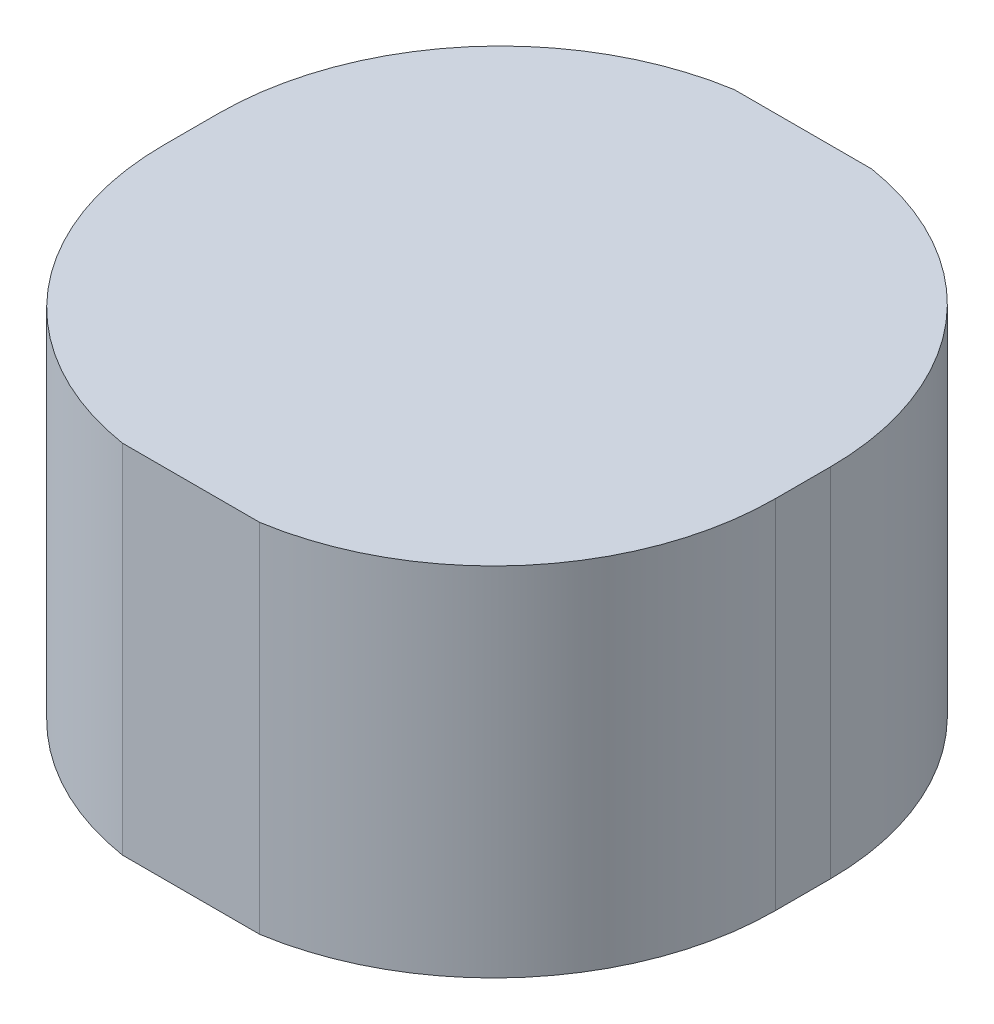
from build123d import *

# Parameters (mm, degrees)
BOSS_EXTRUDE1_DEPTH = 130


with BuildPart() as part:
    # Sketch1 → Boss-Extrude1 (new body)
    with BuildSketch(Plane(origin=(0, 0, 0), x_dir=(1, 0, 0), z_dir=(0, 1, 0))):
        with BuildLine():
            Line((-111.5, -10), (-111.5, 10))
            ThreePointArc((-111.5, 10), (-86.941570736, 76.679269642), (-25, 111.5))
            Line((-25, 111.5), (25, 111.5))
            ThreePointArc((25, 111.5), (86.941570736, 76.679269642), (111.5, 10))
            Line((111.5, 10), (111.5, -10))
            ThreePointArc((111.5, -10), (86.941570736, -76.679269642), (25, -111.5))
            Line((25, -111.5), (-25, -111.5))
            ThreePointArc((-25, -111.5), (-86.941570736, -76.679269642), (-111.5, -10))
        make_face()
    extrude(amount=BOSS_EXTRUDE1_DEPTH)


solid = part.part
